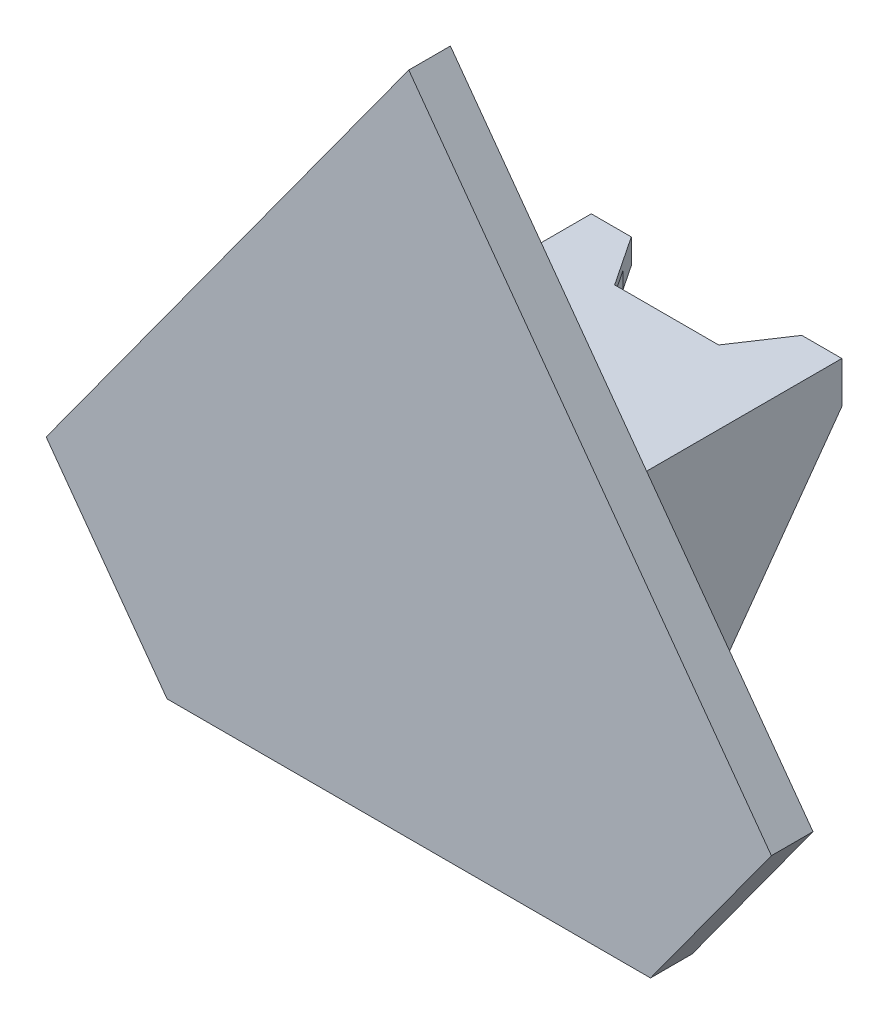
from build123d import *

# Parameters (mm, degrees)
BOSS_EXTRUDE1_DEPTH     = 32.5
SKETCH4_R               = 1.05
BOSS_EXTRUDE2_DEPTH     = 2.5
SKETCH5_R               = 1.05
BOSS_EXTRUDE3_DEPTH     = 3
CUT_EXTRUDE1_DEPTH      = 31.122
BOSS_EXTRUDE4_DEPTH     = 5
BOSS_EXTRUDE6_DEPTH     = 5
CUT_EXTRUDE2_DEPTH      = 6
SKETCH12_W              = 16.4999
SKETCH12_H              = 2
CUT_EXTRUDE4_DEPTH      = 10
CUT_EXTRUDE4_DEPTH_BACK = 23.5


with BuildPart() as part:
    # Sketch2 → Boss-Extrude1 (new body)
    with BuildSketch(Plane(origin=(0, 0, 0), x_dir=(1, 0, 0), z_dir=(0, 1, 0))):
        Polygon((15.061, 0), (15.061, 32), (12.561, 32), (12.561, 2.5), (-12.561, 2.5), (-12.561, 32), (-15.061, 32), (-15.061, 0), align=None)
    extrude(amount=BOSS_EXTRUDE1_DEPTH)

    # Sketch4 → Boss-Extrude2 (add)
    with BuildSketch(Plane.XZ):
        Polygon((-7.5, -6), (7.5, -6), (12.561, -10), (15.061, -10), (15.061, 0), (-15.061, 0), (-15.061, -10), (-12.561, -10), align=None)
        with Locations((-10.2499, -4.95)):
            Circle(SKETCH4_R, mode=Mode.SUBTRACT)
        with Locations((10.2499, -4.95)):
            Circle(SKETCH4_R, mode=Mode.SUBTRACT)
    extrude(amount=BOSS_EXTRUDE2_DEPTH)

    # Sketch5 → Boss-Extrude3 (add)
    with BuildSketch(Plane(origin=(0, 32.5, 0), x_dir=(1, 0, 0), z_dir=(0, 1, 0))):
        Polygon((-15.061, 32), (-10.2499, 32), (-6.25, 26), (6.25, 26), (10.2499, 32), (15.061, 32), (15.061, 0), (-15.061, 0), align=None)
        with Locations((-10.2499, 8.7)):
            Circle(SKETCH5_R, mode=Mode.SUBTRACT)
        with Locations((10.2499, 8.7)):
            Circle(SKETCH5_R, mode=Mode.SUBTRACT)
    extrude(amount=BOSS_EXTRUDE3_DEPTH)

    # Sketch6 → Cut-Extrude1 (cut, through all)
    with BuildSketch(Plane.ZY.offset(15.061)):
        Polygon((-10, 0), (-32, 30.5), (-32, 0), align=None)
    extrude(amount=-CUT_EXTRUDE1_DEPTH, mode=Mode.SUBTRACT)

    # Sketch8 → Boss-Extrude4 (add)
    with BuildSketch(Plane.XY):
        Polygon((0, 76.5), (43.59255168, 16.5), (-43.59255168, 16.5), align=None)
    extrude(amount=BOSS_EXTRUDE4_DEPTH)

    # Sketch9 → Boss-Extrude6 (add)
    with BuildSketch(Plane.XY):
        Polygon((-43.59255168, 16.5), (-58.12340224, -3.5), (58.12340224, -3.5), (43.59255168, 16.5), align=None)
    extrude(amount=BOSS_EXTRUDE6_DEPTH)

    # Sketch10 → Cut-Extrude2 (cut, through all)
    with BuildSketch(Plane(origin=(0, 0, 0), x_dir=(-1, 0, 0), z_dir=(0, 0, -1))):
        Polygon((-29.06170112, -3.5), (-43.59255168, 16.5), (-58.12340224, -3.5), align=None)
        Polygon((58.12340224, -3.5), (43.59255168, 16.5), (29.06170112, -3.5), align=None)
    extrude(amount=-CUT_EXTRUDE2_DEPTH, mode=Mode.SUBTRACT)

    # Sketch12 → Cut-Extrude4 (cut, two sides)
    with BuildSketch(Plane(origin=(0, 0, -26), x_dir=(-1, 0, 0), z_dir=(0, 0, -1))) as cut_extrude4_sk:
        with Locations((0, 33.5)):
            Rectangle(SKETCH12_W, SKETCH12_H)
    extrude(amount=CUT_EXTRUDE4_DEPTH, mode=Mode.SUBTRACT)
    extrude(cut_extrude4_sk.sketch, amount=-CUT_EXTRUDE4_DEPTH_BACK, mode=Mode.SUBTRACT)


solid = part.part
